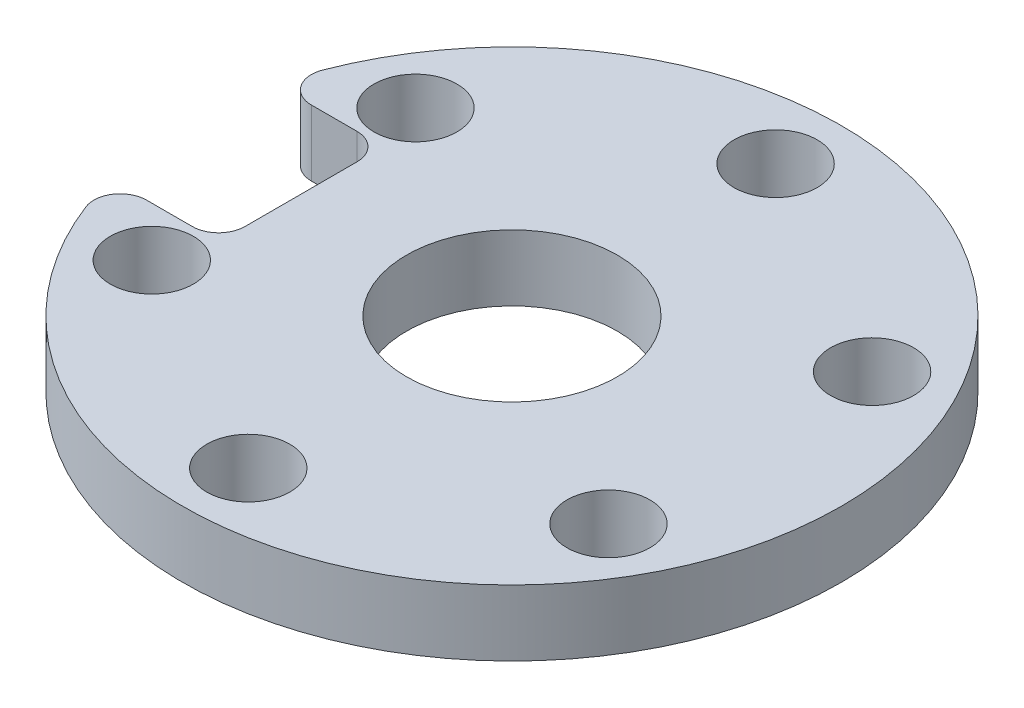
from build123d import *

# Parameters (mm, degrees)
SKETCH_1_R          = 25
SKETCH_1_R_2        = 3.15
EXTRUDE_1_DEPTH     = 5
SKETCH_2_W          = 9
SKETCH_2_H          = 12.5
CUT_EXTRUDE_3_DEPTH = 6
FILLET_1_R          = 2
SKETCH_3_R          = 8
CUT_EXTRUDE_4_DEPTH = 6


with BuildPart() as part:
    # 草图1 → 凸台-拉伸1 (new body)
    with BuildSketch(Plane(origin=(0, 0, 0), x_dir=(1, 0, 0), z_dir=(0, 1, 0))):
        Circle(SKETCH_1_R)
        with Locations((0, 20)):
            Circle(SKETCH_1_R_2, mode=Mode.SUBTRACT)
        with Locations((17.320508076, 10)):
            Circle(SKETCH_1_R_2, mode=Mode.SUBTRACT)
        with Locations((17.320508076, -10)):
            Circle(SKETCH_1_R_2, mode=Mode.SUBTRACT)
        with Locations((0, -20)):
            Circle(SKETCH_1_R_2, mode=Mode.SUBTRACT)
        with Locations((-17.320508076, -10)):
            Circle(SKETCH_1_R_2, mode=Mode.SUBTRACT)
        with Locations((-17.320508076, 10)):
            Circle(SKETCH_1_R_2, mode=Mode.SUBTRACT)
    extrude(amount=EXTRUDE_1_DEPTH)

    # 草图2 → 切除-拉伸3 (cut, through all)
    with BuildSketch(Plane(origin=(0, 0, 0), x_dir=(1, 0, 0), z_dir=(0, 1, 0))):
        with Locations((-20.5, 0)):
            Rectangle(SKETCH_2_W, SKETCH_2_H)
    extrude(amount=CUT_EXTRUDE_3_DEPTH, mode=Mode.SUBTRACT)

    # 圆角1
    fillet_1_edges = [part.edges().sort_by_distance(p)[0] for p in [
        (-24.206145914, 2.5, -6.25),
        (-24.206145914, 2.5, 6.25),
        (-16, 2.5, -6.25),
        (-16, 2.5, 6.25),
    ]]
    fillet(fillet_1_edges, radius=FILLET_1_R)

    # 草图3 → 切除-拉伸4 (cut, through all)
    with BuildSketch(Plane(origin=(0, 5, 0), x_dir=(1, 0, 0), z_dir=(0, 1, 0))):
        Circle(SKETCH_3_R)
    extrude(amount=-CUT_EXTRUDE_4_DEPTH, mode=Mode.SUBTRACT)


solid = part.part
